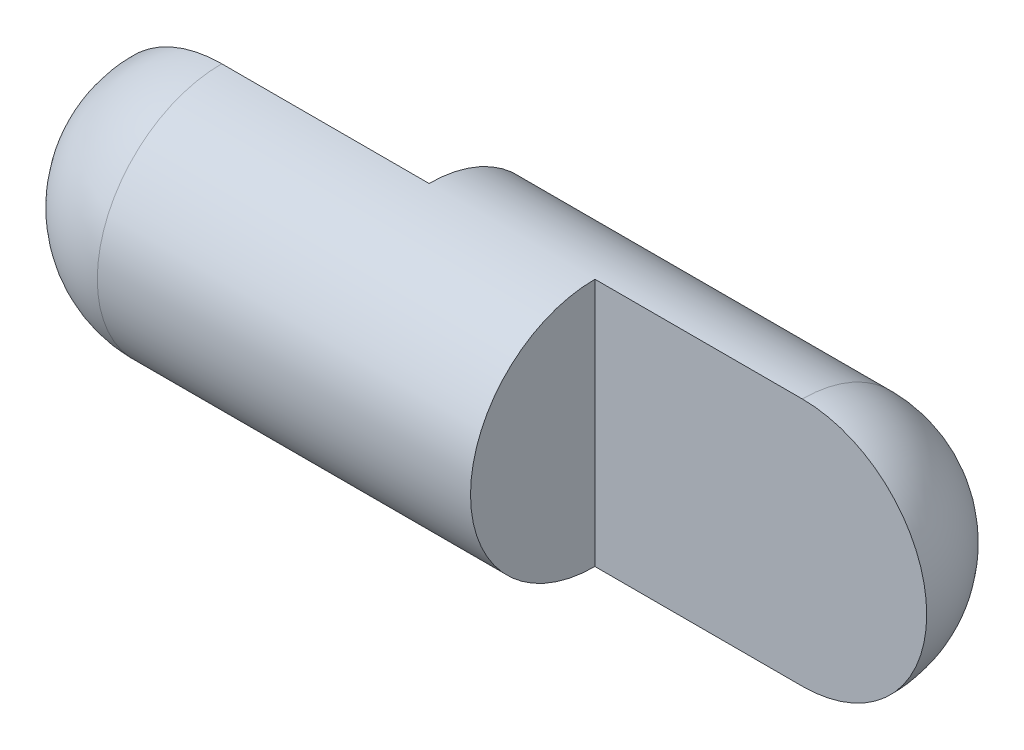
from build123d import *

# Parameters (mm, degrees)
REVOLVE1_ANGLE = 180
REVOLVE2_ANGLE = 180


with BuildPart() as part:
    # Sketch1 → Revolve1 (revolve)
    with BuildSketch(Plane.XY):
        with BuildLine():
            Line((0, 75), (225, 75))
            Line((225, 75), (225, 0))
            Line((225, 0), (-75, 0))
            ThreePointArc((-75, 0), (-53.033008589, 53.033008589), (0, 75))
        make_face()
    revolve(axis=Axis((-97.796083429, 0, 0), (1, 0, 0)), revolution_arc=REVOLVE1_ANGLE)

    # Sketch1_4 → Revolve2 (revolve)
    with BuildSketch(Plane.XY):
        with BuildLine():
            Line((425, 0), (225, 0))
            Line((225, 0), (125, 0))
            Line((125, 0), (125, -75))
            Line((125, -75), (350, -75))
            ThreePointArc((350, -75), (403.033008589, -53.033008589), (425, 0))
        make_face()
    revolve(axis=Axis((-97.796083429, 0, 0), (1, 0, 0)), revolution_arc=REVOLVE2_ANGLE)


solid = part.part
